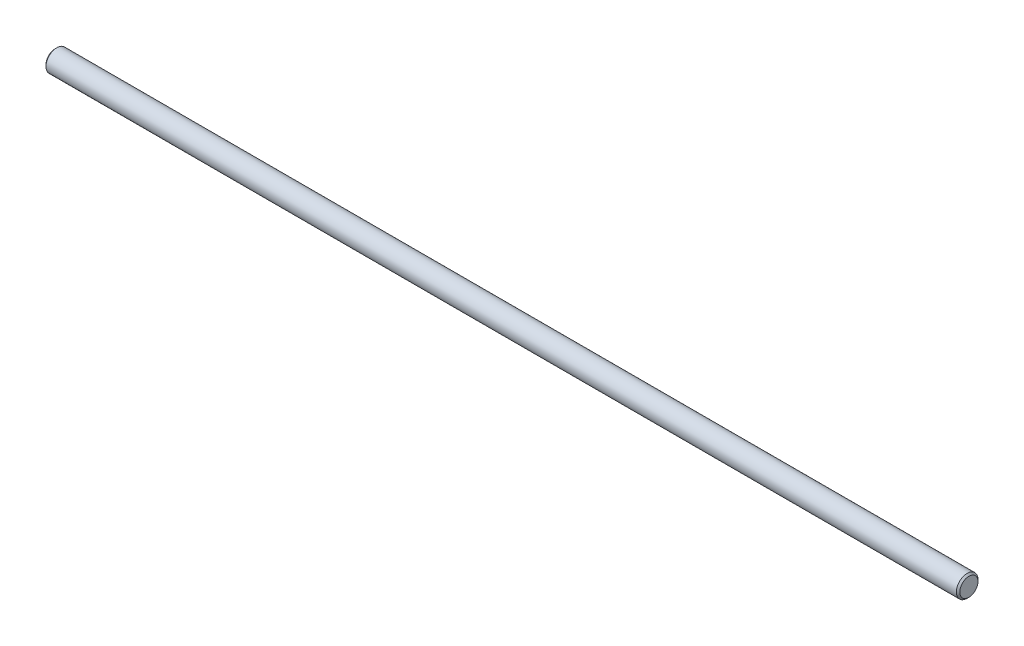
from build123d import *

# Parameters (mm, degrees)
SKETCH1_R           = 6.35
BOSS_EXTRUDE1_DEPTH = 268
CHAMFER1_SIZE       = 1
CHAMFER2_SIZE       = 1


with BuildPart() as part:
    # Sketch1 → Boss-Extrude1 (new body, symmetric)
    with BuildSketch(Plane(origin=(0, 0, 0), x_dir=(0, 0, -1), z_dir=(1, 0, 0))):
        Circle(SKETCH1_R)
    extrude(amount=BOSS_EXTRUDE1_DEPTH, both=True)

    # Chamfer1
    chamfer1_edges = [part.edges().sort_by_distance(p)[0] for p in [
        (-268, 0, 6.35),
    ]]
    chamfer(chamfer1_edges, length=CHAMFER1_SIZE)

    # Chamfer2
    chamfer2_edges = [part.edges().sort_by_distance(p)[0] for p in [
        (268, 0, 6.35),
    ]]
    chamfer(chamfer2_edges, length=CHAMFER2_SIZE)


solid = part.part
